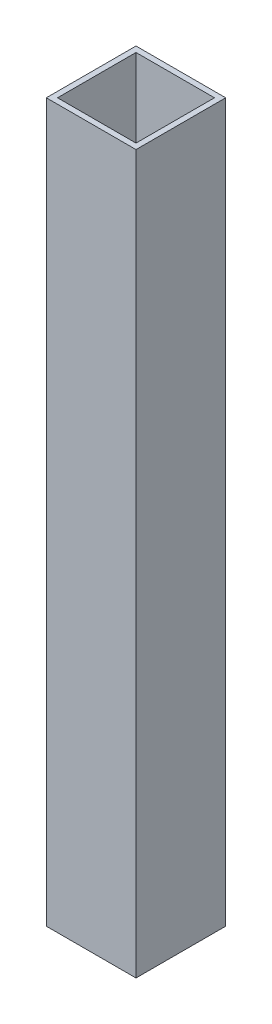
from build123d import *

# Parameters (mm, degrees)
SKETCH1_W           = 25.4
SKETCH1_H           = 25.4
SKETCH1_W_2         = 22.225
SKETCH1_H_2         = 22.225
BOSS_EXTRUDE1_DEPTH = 203.2


with BuildPart() as part:
    # Sketch1 → Boss-Extrude1 (new body)
    with BuildSketch(Plane(origin=(0, 0, 0), x_dir=(1, 0, 0), z_dir=(0, 1, 0))):
        Rectangle(SKETCH1_W, SKETCH1_H)
        Rectangle(SKETCH1_W_2, SKETCH1_H_2, mode=Mode.SUBTRACT)
    extrude(amount=BOSS_EXTRUDE1_DEPTH)


solid = part.part
